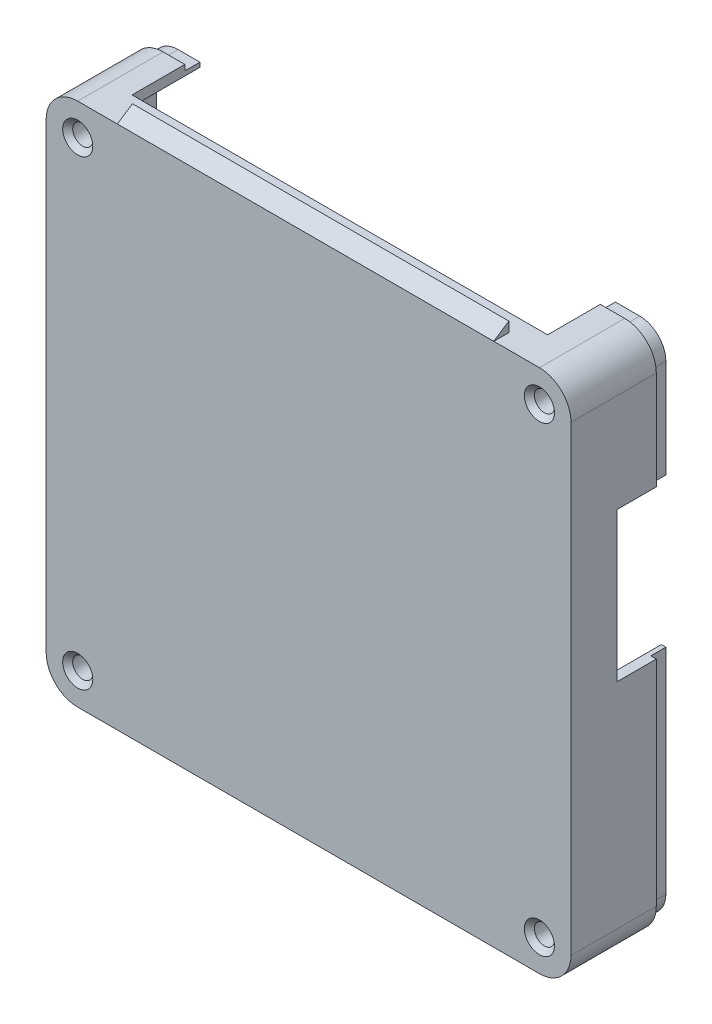
from build123d import *

# Parameters (mm, degrees)
SKETCH1_R                = 3.25
BOSS_EXTRUDE1_DEPTH      = 3
BOSS_EXTRUDE1_2_DEPTH    = 3
BOSS_EXTRUDE1_3_DEPTH    = 3
BOSS_EXTRUDE1_4_DEPTH    = 3
BOSS_EXTRUDE2_DEPTH      = 2
BOSS_EXTRUDE3_DEPTH      = 20
SKETCH4_R                = 2
CUT_EXTRUDE1_DEPTH       = 5
CUT_EXTRUDE2_REACH       = 106.575
SKETCH6_W                = 82.790515713
SKETCH6_H                = 14.032058418
CUT_EXTRUDE3_REACH       = 106.575
SKETCH7_W                = 17
SKETCH7_H                = 29.705346692
CHAMFER1_SIZE            = 1
CUT_EXTRUDE4_DEPTH       = 3
BOSS_EXTRUDE4_DEPTH      = 65
BOSS_EXTRUDE4_DEPTH_BACK = 10


with BuildPart() as part:
    # Sketch1 → Boss-Extrude1 (new body)
    with BuildSketch(Plane(origin=(0, 0, 89.352648697), x_dir=(-1, 0, 0), z_dir=(0, 0, 1))):
        with Locations((-74.099367844, 104.955675546)):
            Circle(SKETCH1_R)
    extrude(amount=BOSS_EXTRUDE1_DEPTH)



with BuildPart() as body_2:
    # Sketch1 → Boss-Extrude1 2 (new body)
    with BuildSketch(Plane(origin=(0, 0, 89.352648697), x_dir=(-1, 0, 0), z_dir=(0, 0, 1))):
        with Locations((17.900817576, 104.955675546)):
            Circle(SKETCH1_R)
    extrude(amount=BOSS_EXTRUDE1_2_DEPTH)


with BuildPart() as body_3:
    # Sketch1 → Boss-Extrude1 3 (new body)
    with BuildSketch(Plane(origin=(0, 0, 89.352648697), x_dir=(-1, 0, 0), z_dir=(0, 0, 1))):
        with Locations((17.900817576, 12.955490126)):
            Circle(SKETCH1_R)
    extrude(amount=BOSS_EXTRUDE1_3_DEPTH)


with BuildPart() as body_4:
    # Sketch1 → Boss-Extrude1 4 (new body)
    with BuildSketch(Plane(origin=(0, 0, 89.352648697), x_dir=(-1, 0, 0), z_dir=(0, 0, 1))):
        with Locations((-74.099367844, 12.955490126)):
            Circle(SKETCH1_R)
    extrude(amount=BOSS_EXTRUDE1_4_DEPTH)


with BuildPart() as part_1:
    add(part.part)

    add(body_2.part)  # Boss-Extrude2 merges body 2

    add(body_3.part)  # Boss-Extrude2 merges body 3

    add(body_4.part)  # Boss-Extrude2 merges body 4
    # Sketch2 → Boss-Extrude2 (add)
    with BuildSketch(Plane(origin=(0, 0, 92.352648697), x_dir=(-1, 0, 0), z_dir=(0, 0, 1))):
        with BuildLine():
            Line((17.900817576, 109.242983141), (-74.099367844, 109.242983141))
            ThreePointArc((-74.099367844, 109.242983141), (-77.130952117, 107.987259819), (-78.386675439, 104.955675546))
            Line((-78.386675439, 104.955675546), (-78.386675439, 12.955490126))
            ThreePointArc((-78.386675439, 12.955490126), (-77.130952117, 9.923905853), (-74.099367844, 8.668182531))
            Line((-74.099367844, 8.668182531), (17.900817576, 8.668182531))
            ThreePointArc((17.900817576, 8.668182531), (20.93240185, 9.923905853), (22.188125171, 12.955490126))
            Line((22.188125171, 12.955490126), (22.188125171, 104.955675546))
            ThreePointArc((22.188125171, 104.955675546), (20.93240185, 107.987259819), (17.900817576, 109.242983141))
        make_face()
    extrude(amount=BOSS_EXTRUDE2_DEPTH)

    # Sketch3 → Boss-Extrude3 (add)
    with BuildSketch(Plane(origin=(0, 0, 94.352648697), x_dir=(-1, 0, 0), z_dir=(0, 0, 1))):
        with BuildLine():
            Line((17.900817576, 111.242983141), (-74.099367844, 111.242983141))
            ThreePointArc((-74.099367844, 111.242983141), (-78.54516568, 109.401473382), (-80.386675439, 104.955675546))
            Line((-80.386675439, 104.955675546), (-80.386675439, 12.955490126))
            ThreePointArc((-80.386675439, 12.955490126), (-78.54516568, 8.50969229), (-74.099367844, 6.668182531))
            Line((-74.099367844, 6.668182531), (17.900817576, 6.668182531))
            ThreePointArc((17.900817576, 6.668182531), (22.346615412, 8.50969229), (24.188125171, 12.955490126))
            Line((24.188125171, 12.955490126), (24.188125171, 104.955675546))
            ThreePointArc((24.188125171, 104.955675546), (22.346615412, 109.401473382), (17.900817576, 111.242983141))
        make_face()
        with BuildLine():
            Line((17.900817576, 109.242983141), (-74.099367844, 109.242983141))
            ThreePointArc((-74.099367844, 109.242983141), (-77.130952117, 107.987259819), (-78.386675439, 104.955675546))
            Line((-78.386675439, 104.955675546), (-78.386675439, 12.955490126))
            ThreePointArc((-78.386675439, 12.955490126), (-77.130952117, 9.923905853), (-74.099367844, 8.668182531))
            Line((-74.099367844, 8.668182531), (17.900817576, 8.668182531))
            ThreePointArc((17.900817576, 8.668182531), (20.93240185, 9.923905853), (22.188125171, 12.955490126))
            Line((22.188125171, 12.955490126), (22.188125171, 104.955675546))
            ThreePointArc((22.188125171, 104.955675546), (20.93240185, 107.987259819), (17.900817576, 109.242983141))
        make_face(mode=Mode.SUBTRACT)
    extrude(amount=-BOSS_EXTRUDE3_DEPTH)

    # Sketch4 → Cut-Extrude1 (cut)
    with BuildSketch(Plane(origin=(0, 0, 89.352648697), x_dir=(1, 0, 0), z_dir=(0, 0, -1))):
        with Locations((-17.900817576, 104.955675546)):
            Circle(SKETCH4_R)
        with Locations((74.099367844, 104.955675546)):
            Circle(SKETCH4_R)
        with Locations((74.099367844, 12.955490126)):
            Circle(SKETCH4_R)
        with Locations((-17.900817576, 12.955490126)):
            Circle(SKETCH4_R)
    extrude(amount=-CUT_EXTRUDE1_DEPTH, mode=Mode.SUBTRACT)

    # Sketch6 → Cut-Extrude2 (cut, up to next)
    with BuildSketch(Plane(origin=(0, -6.668182531, 0), x_dir=(1, 0, 0), z_dir=(0, 1, 0)), mode=Mode.PRIVATE) as cut_extrude2_sk1:
        with Locations((27.842461798, -80.850462516)):
            Rectangle(SKETCH6_W, SKETCH6_H)
    cut_extrude2_tool1 = extrude(cut_extrude2_sk1.sketch, amount=-CUT_EXTRUDE2_REACH, mode=Mode.PRIVATE) & part_1.part
    add(cut_extrude2_tool1.solids().sort_by_distance((27.842462, -6.668183, 80.850463))[0], mode=Mode.SUBTRACT)

    # Sketch7 → Cut-Extrude3 (cut, up to next)
    with BuildSketch(Plane(origin=(80.386675439, 0, 0), x_dir=(0, 0, -1), z_dir=(1, 0, 0)), mode=Mode.PRIVATE) as cut_extrude3_sk1:
        with Locations((-76.666440925, -47.447220968)):
            Rectangle(SKETCH7_W, SKETCH7_H)
    cut_extrude3_tool1 = extrude(cut_extrude3_sk1.sketch, amount=-CUT_EXTRUDE3_REACH, mode=Mode.PRIVATE) & part_1.part
    add(cut_extrude3_tool1.solids().sort_by_distance((80.386675, -47.447221, 76.666441))[0], mode=Mode.SUBTRACT)

    # Chamfer1
    chamfer1_edges = [part_1.edges().sort_by_distance(p)[0] for p in [
        (-19.900817576, -12.955490126, 94.352648697),
        (72.099367844, -12.955490126, 94.352648697),
        (72.099367844, -104.955675546, 94.352648697),
        (-19.900817576, -104.955675546, 94.352648697),
    ]]
    chamfer(chamfer1_edges, length=CHAMFER1_SIZE)

    # Sketch10 → Cut-Extrude4 (cut)
    with BuildSketch(Plane(origin=(0, 0, 74.352648697), x_dir=(-1, 0, 0), z_dir=(0, 0, -1))):
        with BuildLine():
            Line((-80.386675439, -12.955490126), (-80.386675439, -32.594547622))
            Line((-80.386675439, -32.594547622), (-80.386675439, -62.299894314))
            Line((-80.386675439, -62.299894314), (-80.386675439, -104.955675546))
            ThreePointArc((-80.386675439, -104.955675546), (-78.54516568, -109.401473382), (-74.099367844, -111.242983141))
            Line((-74.099367844, -111.242983141), (17.900817576, -111.242983141))
            ThreePointArc((17.900817576, -111.242983141), (22.346615412, -109.401473382), (24.188125171, -104.955675546))
            Line((24.188125171, -104.955675546), (24.188125171, -12.955490126))
            ThreePointArc((24.188125171, -12.955490126), (22.346615412, -8.50969229), (17.900817576, -6.668182531))
            Line((17.900817576, -6.668182531), (13.552796059, -6.668182531))
            Line((13.552796059, -6.668182531), (-69.237719654, -6.668182531))
            Line((-69.237719654, -6.668182531), (-74.099367844, -6.668182531))
            ThreePointArc((-74.099367844, -6.668182531), (-78.54516568, -8.50969229), (-80.386675439, -12.955490126))
        make_face()
        with BuildLine():
            Line((-79.286675439, -32.594547622), (-79.286675439, -62.299894314))
            Line((-79.286675439, -62.299894314), (-79.286675439, -104.955675546))
            ThreePointArc((-79.286675439, -104.955675546), (-77.76734822, -108.623655922), (-74.099367844, -110.142983141))
            Line((-74.099367844, -110.142983141), (17.900817576, -110.142983141))
            ThreePointArc((17.900817576, -110.142983141), (21.568797953, -108.623655922), (23.088125171, -104.955675546))
            Line((23.088125171, -104.955675546), (23.088125171, -12.955490126))
            ThreePointArc((23.088125171, -12.955490126), (21.568797953, -9.28750975), (17.900817576, -7.768182531))
            Line((17.900817576, -7.768182531), (13.552796059, -7.768182531))
            Line((13.552796059, -7.768182531), (-69.237719654, -7.768182531))
            Line((-69.237719654, -7.768182531), (-74.099367844, -7.768182531))
            ThreePointArc((-74.099367844, -7.768182531), (-77.76734822, -9.28750975), (-79.286675439, -12.955490126))
            Line((-79.286675439, -12.955490126), (-79.286675439, -32.594547622))
        make_face(mode=Mode.SUBTRACT)
    extrude(amount=-CUT_EXTRUDE4_DEPTH, mode=Mode.SUBTRACT)

    # Sketch11 → Boss-Extrude4 (add, two sides)
    with BuildSketch(Plane(origin=(0, 0, 0), x_dir=(0, 0, -1), z_dir=(1, 0, 0))) as boss_extrude4_sk:
        Polygon((-94.352648697, -6.668182531), (-91.352648697, -4.668182531), (-91.352648697, -6.668182531), align=None)
        Polygon((-94.352648697, -111.242983141), (-91.352648697, -111.242983141), (-91.352648697, -113.242983141), align=None)
    extrude(amount=BOSS_EXTRUDE4_DEPTH)
    extrude(boss_extrude4_sk.sketch, amount=-BOSS_EXTRUDE4_DEPTH_BACK)


solid = part_1.part
